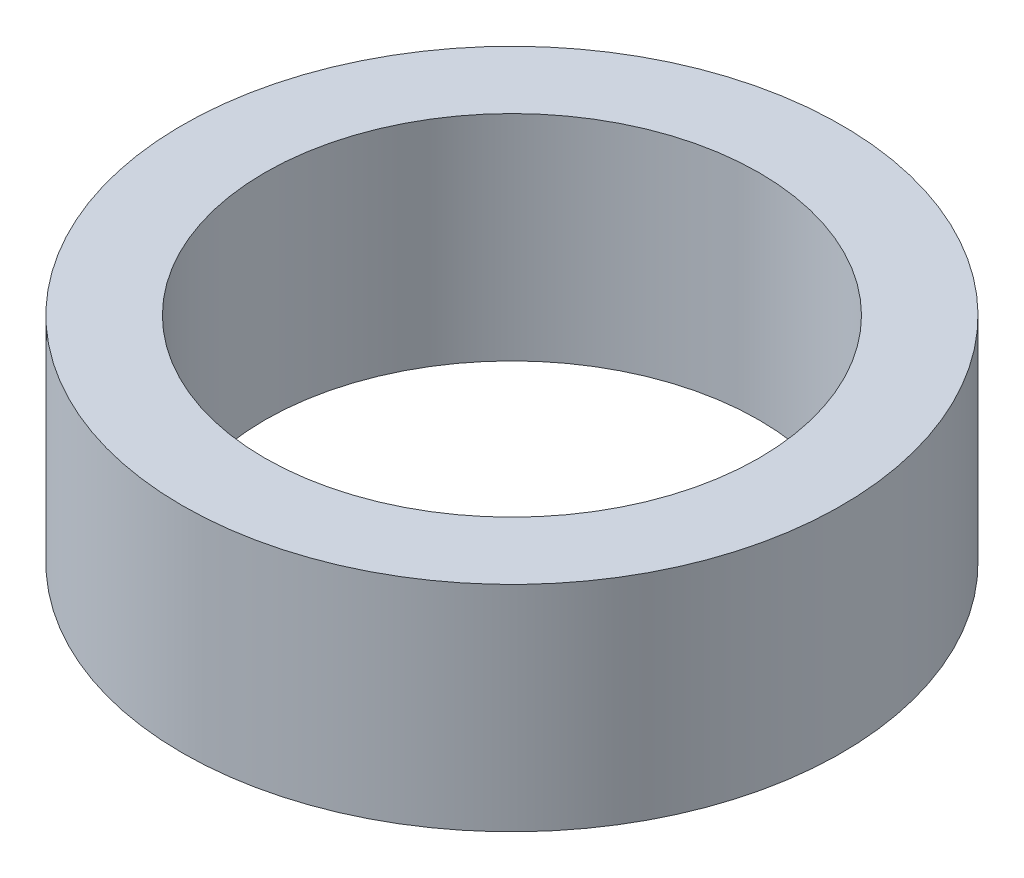
from build123d import *

# Parameters (mm, degrees)
SKETCH1_R           = 12.7
SKETCH1_R_2         = 9.525
BOSS_EXTRUDE1_DEPTH = 8.255


with BuildPart() as part:
    # Sketch1 → Boss-Extrude1 (new body)
    with BuildSketch(Plane(origin=(0, 0, 0), x_dir=(1, 0, 0), z_dir=(0, 1, 0))):
        Circle(SKETCH1_R)
        Circle(SKETCH1_R_2, mode=Mode.SUBTRACT)
    extrude(amount=BOSS_EXTRUDE1_DEPTH)


solid = part.part
